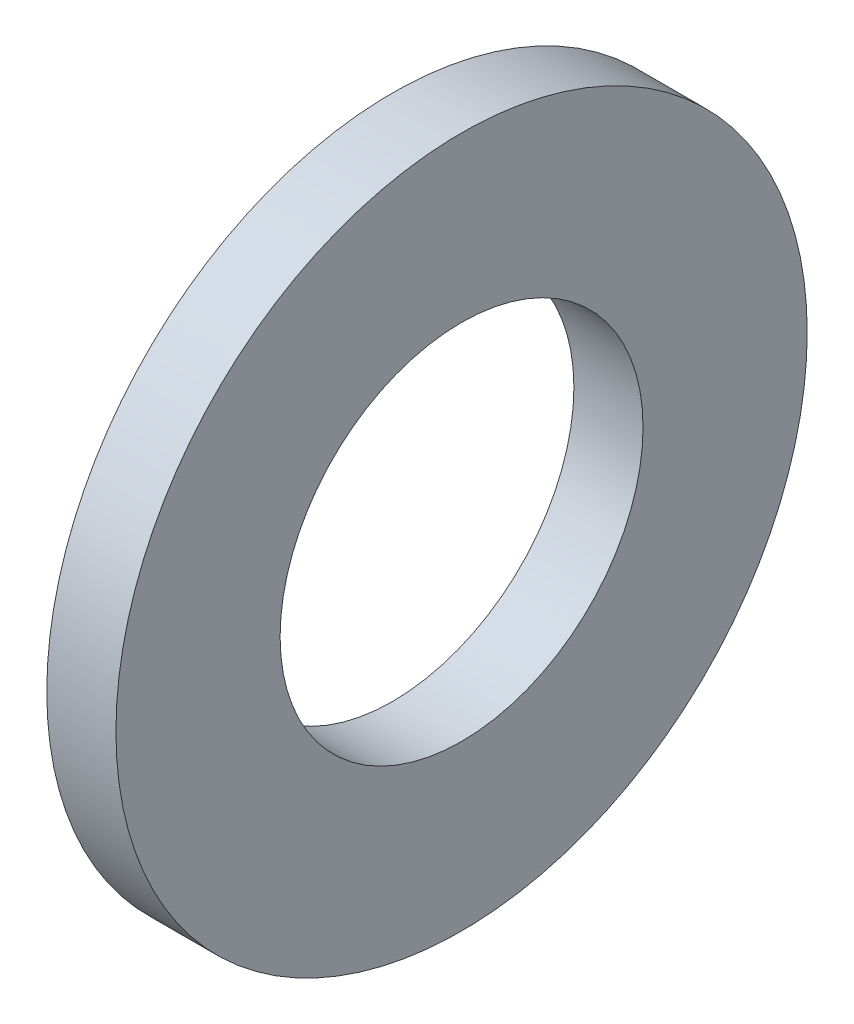
from build123d import *

# Parameters (mm, degrees)
SZKIC1_W = 2
SZKIC1_H = 4.75


with BuildPart() as part:
    # Szkic1 → Obrót1 (revolve)
    with BuildSketch(Plane.XY):
        with Locations((5.715556568, 7.625)):
            Rectangle(SZKIC1_W, SZKIC1_H)
    revolve(axis=Axis((0, 0, 0), (1, 0, 0)))


solid = part.part
